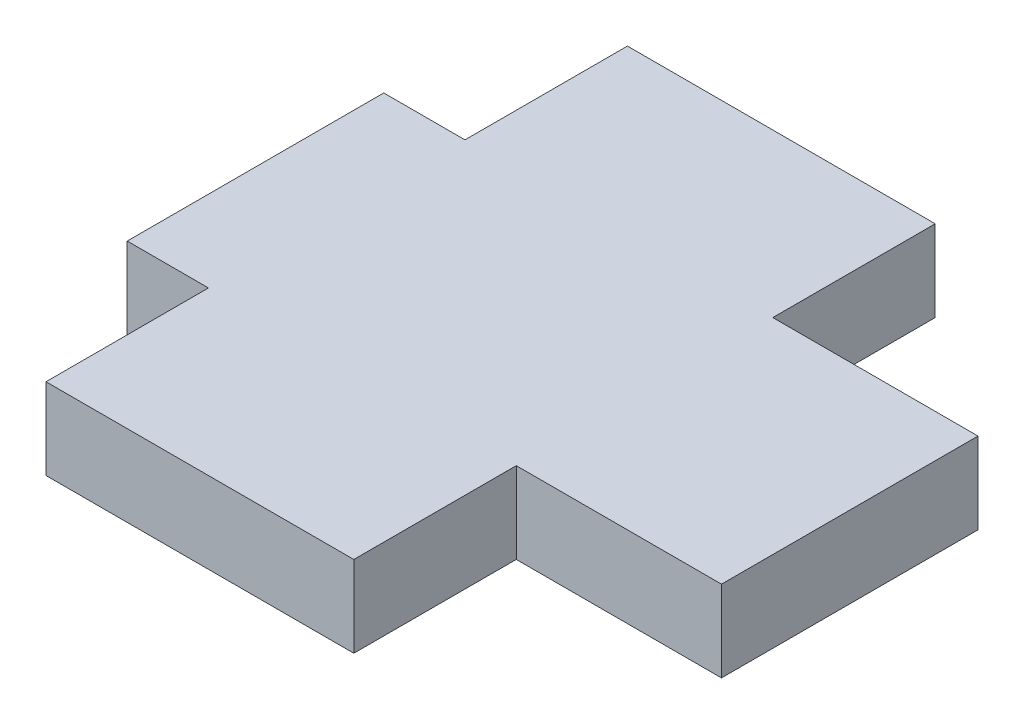
from build123d import *

# Parameters (mm, degrees)
BOSS_EXTRUDE1_DEPTH = 6.0325


with BuildPart() as part:
    # Sketch1 → Boss-Extrude1 (new body)
    with BuildSketch(Plane(origin=(0, 0, 0), x_dir=(1, 0, 0), z_dir=(0, 1, 0))):
        Polygon((0, 0), (22.86, 0), (22.86, 12.065), (38.1, 12.065), (38.1, 31.115), (22.86, 31.115), (22.86, 43.18), (0, 43.18), (0, 31.115), (-6.0325, 31.115), (-6.0325, 12.065), (0, 12.065), align=None)
    extrude(amount=BOSS_EXTRUDE1_DEPTH)


solid = part.part
